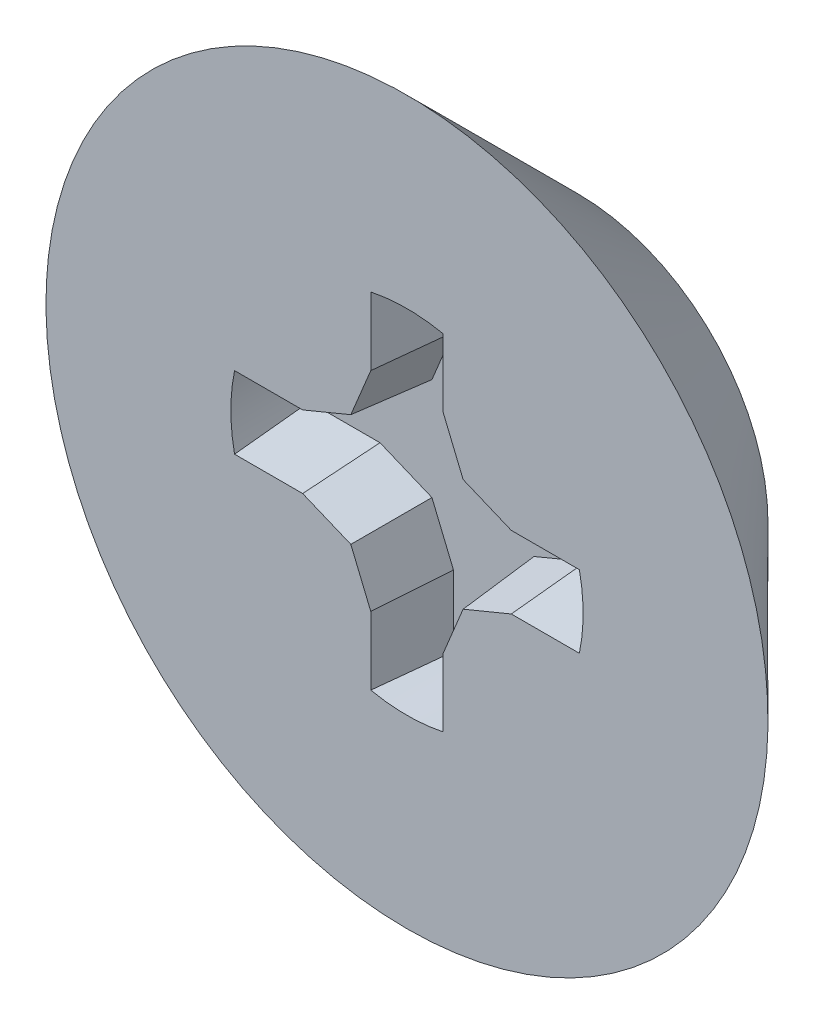
from build123d import *

# Parameters (mm, degrees)
CUT_EXTRUDE1_DEPTH = 0.4
CIRPATTERN1_COUNT  = 4
DRAFT2_ANGLE       = 5


with BuildPart() as part:
    # Sketch3 → Revolve1 (revolve)
    with BuildSketch(Plane(origin=(0, 0, 0), x_dir=(0, 0, -1), z_dir=(1, 0, 0)), mode=Mode.PRIVATE) as revolve1_sk:
        Polygon((-1.2, 0), (-1.2, 1.9), (-0.3, 1), (-0.3, 0), align=None)
    revolve(revolve1_sk.sketch.rotate(Axis((0, 0, 1.2), (0, 0, -1)), 180), axis=Axis((0, 0, 1.2), (0, 0, -1)))

    # Sketch4 → Cut-Extrude1 (cut)
    with BuildSketch(Plane.XY.offset(1.2)):
        with BuildLine():
            Line((0, 0), (0.9271, 0))
            ThreePointArc((0.9271, 0), (0.92214099, 0.095762227), (0.907317012, 0.1905))
            Line((0.907317012, 0.1905), (0.548908506, 0.1905))
            Line((0.548908506, 0.1905), (0.295475421, 0.295475421))
            Line((0.295475421, 0.295475421), (0.1905, 0.548908506))
            Line((0.1905, 0.548908506), (0.1905, 0.907317012))
            ThreePointArc((0.1905, 0.907317012), (0.095762227, 0.92214099), (0, 0.9271))
            Line((0, 0.9271), (0, 0))
        make_face()
    cut_extrude1 = extrude(amount=-CUT_EXTRUDE1_DEPTH, mode=Mode.SUBTRACT)

    # CirPattern1: Cut-Extrude1 ×4 about axis
    cirpattern1_axis = Axis((0, 0, 0), (0, 0, 1))
    for i in range(1, CIRPATTERN1_COUNT):
        add(cut_extrude1.rotate(cirpattern1_axis, i * 360 / CIRPATTERN1_COUNT), mode=Mode.SUBTRACT)

    # Draft2
    draft2_faces = [part.faces().sort_by_distance(p)[0] for p in [
        (-0.728112759, 0.1905, 1),
        (-0.422191963, 0.24298771, 1),
        (-0.24298771, 0.422191963, 1),
        (-0.1905, 0.728112759, 1),
        (0.1905, 0.728112759, 1),
        (0.24298771, 0.422191963, 1),
        (0.422191963, 0.24298771, 1),
        (0.728112759, 0.1905, 1),
        (0.728112759, -0.1905, 1),
        (0.422191963, -0.24298771, 1),
        (0.24298771, -0.422191963, 1),
        (0.1905, -0.728112759, 1),
        (-0.1905, -0.728112759, 1),
        (-0.24298771, -0.422191963, 1),
        (-0.422191963, -0.24298771, 1),
        (-0.728112759, -0.1905, 1),
    ]]
    draft(draft2_faces, Plane(origin=(0, 0, 1.2), x_dir=(0, 1, 0), z_dir=(0, 0, 1)), DRAFT2_ANGLE)


solid = part.part
